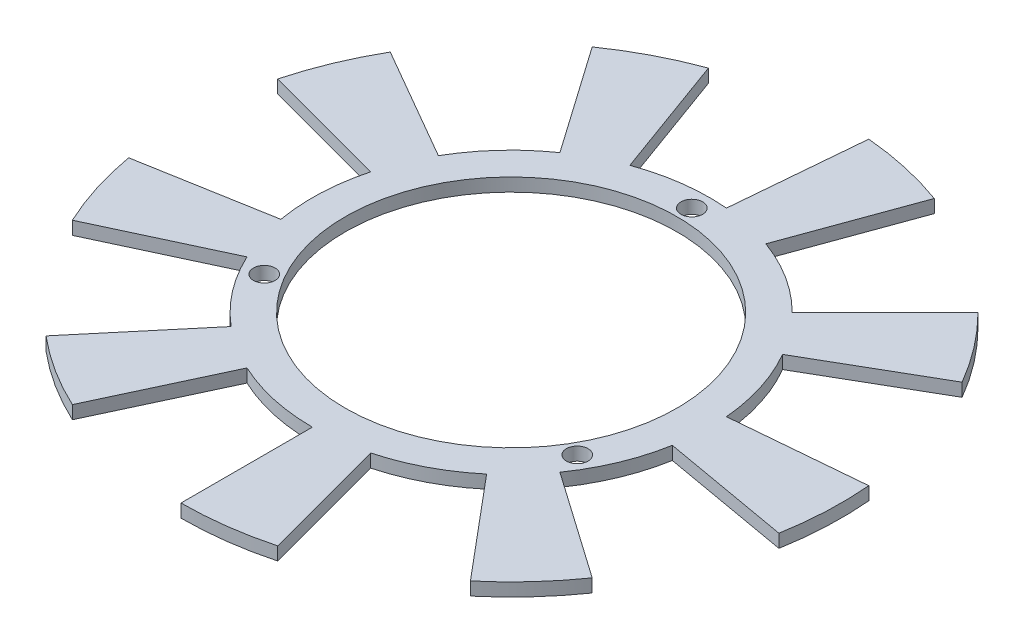
from build123d import *

# Parameters (mm, degrees)
SKETCH1_R           = 30.25
SKETCH1_R_2         = 25.25
EXTRUDE_THIN1_DEPTH = 2
SKETCH2_R           = 1.65
CUT_EXTRUDE3_DEPTH  = 10
BOSS_EXTRUDE1_DEPTH = 2


with BuildPart() as part:
    # Sketch1 → Extrude-Thin1 (new body)
    with BuildSketch(Plane(origin=(0, 0, 0), x_dir=(1, 0, 0), z_dir=(0, 1, 0))):
        Circle(SKETCH1_R)
        Circle(SKETCH1_R_2, mode=Mode.SUBTRACT)
    extrude(amount=-EXTRUDE_THIN1_DEPTH)

    # Sketch2 → Cut-Extrude3 (cut)
    with BuildSketch(Plane(origin=(0, 0, 0), x_dir=(1, 0, 0), z_dir=(0, 1, 0))):
        with Locations((0, 27.5)):
            Circle(SKETCH2_R)
        with Locations((23.815698604, -13.75)):
            Circle(SKETCH2_R)
        with Locations((-23.815698604, -13.75)):
            Circle(SKETCH2_R)
    extrude(amount=-CUT_EXTRUDE3_DEPTH, mode=Mode.SUBTRACT)

    # Sketch5 → Boss-Extrude1 (add)
    with BuildSketch(Plane.XZ.offset(2)):
        with BuildLine():
            Line((0, 50.25), (0, 30.25))
            ThreePointArc((0, 30.25), (3.948417315, 29.991207057), (7.829276114, 29.219256245))
            Line((7.829276114, 29.219256245), (13.005657016, 48.537772771))
            ThreePointArc((13.005657016, 48.537772771), (6.558941159, 49.820104284), (0, 50.25))
        make_face()
        with BuildLine():
            Line((32.300077387, 38.493733267), (19.444325193, 23.172844404))
            ThreePointArc((19.444325193, 23.172844404), (22.302639439, 20.43660378), (24.77934934, 17.3506872))
            Line((24.77934934, 17.3506872), (41.162390226, 28.822215927))
            ThreePointArc((41.162390226, 28.822215927), (37.048186175, 33.948407933), (32.300077387, 38.493733267))
        make_face()
        with BuildLine():
            Line((49.486589589, 8.725820928), (29.790434529, 5.252857374))
            ThreePointArc((29.790434529, 5.252857374), (30.221208703, 1.319486468), (30.134889617, -2.636461218))
            Line((30.134889617, -2.636461218), (50.058783579, -4.379576073))
            ThreePointArc((50.058783579, -4.379576073), (50.202173134, 2.191874215), (49.486589589, 8.725820928))
        make_face()
        with BuildLine():
            Line((43.51777654, -25.125), (26.197268464, -15.125))
            ThreePointArc((26.197268464, -15.125), (23.998938544, -18.415033228), (21.389980131, -21.389980131))
            Line((21.389980131, -21.389980131), (35.532115755, -35.532115755))
            ThreePointArc((35.532115755, -35.532115755), (39.86600535, -30.590261808), (43.51777654, -25.125))
        make_face()
        with BuildLine():
            Line((17.186512202, -47.219554194), (10.346109336, -28.425701779))
            ThreePointArc((10.346109336, -28.425701779), (6.547298322, -29.532954215), (2.636461218, -30.134889617))
            Line((2.636461218, -30.134889617), (4.379576073, -50.058783579))
            ThreePointArc((4.379576073, -50.058783579), (10.8760906, -49.058874358), (17.186512202, -47.219554194))
        make_face()
        with BuildLine():
            Line((-17.186512202, -47.219554194), (-10.346109336, -28.425701779))
            ThreePointArc((-10.346109336, -28.425701779), (-13.96789555, -26.832077704), (-17.3506872, -24.77934934))
            Line((-17.3506872, -24.77934934), (-28.822215927, -41.162390226))
            ThreePointArc((-28.822215927, -41.162390226), (-23.202867815, -44.572294367), (-17.186512202, -47.219554194))
        make_face()
        with BuildLine():
            Line((-43.51777654, -25.125), (-26.197268464, -15.125))
            ThreePointArc((-26.197268464, -15.125), (-27.947355858, -11.576173829), (-29.219256245, -7.829276114))
            Line((-29.219256245, -7.829276114), (-48.537772771, -13.005657016))
            ThreePointArc((-48.537772771, -13.005657016), (-46.424946509, -19.229842476), (-43.51777654, -25.125))
        make_face()
        with BuildLine():
            Line((-49.486589589, 8.725820928), (-29.790434529, 5.252857374))
            ThreePointArc((-29.790434529, 5.252857374), (-28.84993776, 9.096350435), (-27.415810558, 12.784202418))
            Line((-27.415810558, 12.784202418), (-45.541966299, 21.236567652))
            ThreePointArc((-45.541966299, 21.236567652), (-47.924276775, 15.110466425), (-49.486589589, 8.725820928))
        make_face()
        with BuildLine():
            Line((-32.300077387, 38.493733267), (-19.444325193, 23.172844404))
            ThreePointArc((-19.444325193, 23.172844404), (-16.253313152, 25.512591236), (-12.784202418, 27.415810558))
            Line((-12.784202418, 27.415810558), (-21.236567652, 45.541966299))
            ThreePointArc((-21.236567652, 45.541966299), (-26.999305319, 42.380420152), (-32.300077387, 38.493733267))
        make_face()
    extrude(amount=-BOSS_EXTRUDE1_DEPTH)


solid = part.part
